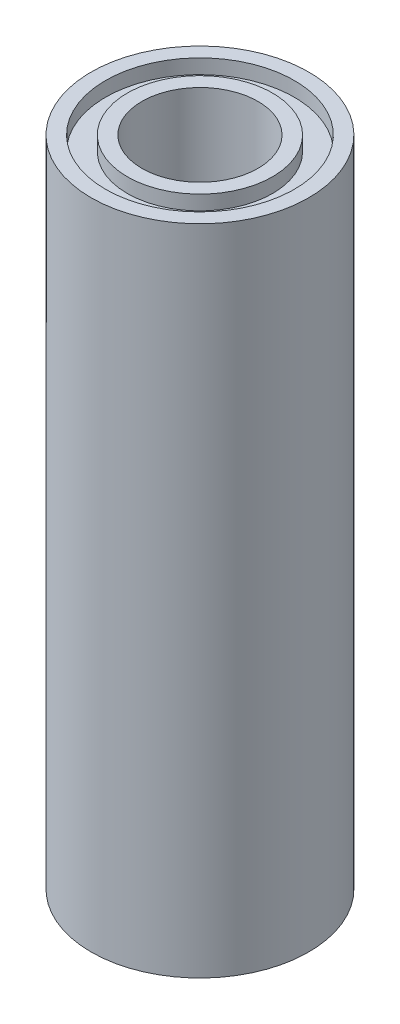
from build123d import *

# Parameters (mm, degrees)
SKETCH1_R           = 7.5
SKETCH1_R_2         = 4
BOSS_EXTRUDE1_DEPTH = 45
SKETCH2_R           = 6.5
SKETCH2_R_2         = 5
CUT_EXTRUDE1_DEPTH  = 1


with BuildPart() as part:
    # Sketch1 → Boss-Extrude1 (new body)
    with BuildSketch(Plane(origin=(0, 0, 0), x_dir=(1, 0, 0), z_dir=(0, 1, 0))):
        Circle(SKETCH1_R)
        Circle(SKETCH1_R_2, mode=Mode.SUBTRACT)
    extrude(amount=BOSS_EXTRUDE1_DEPTH)

    # Sketch2 → Cut-Extrude1 (cut)
    with BuildSketch(Plane(origin=(0, 45, 0), x_dir=(1, 0, 0), z_dir=(0, 1, 0))):
        Circle(SKETCH2_R)
        Circle(SKETCH2_R_2, mode=Mode.SUBTRACT)
    extrude(amount=-CUT_EXTRUDE1_DEPTH, mode=Mode.SUBTRACT)


solid = part.part
